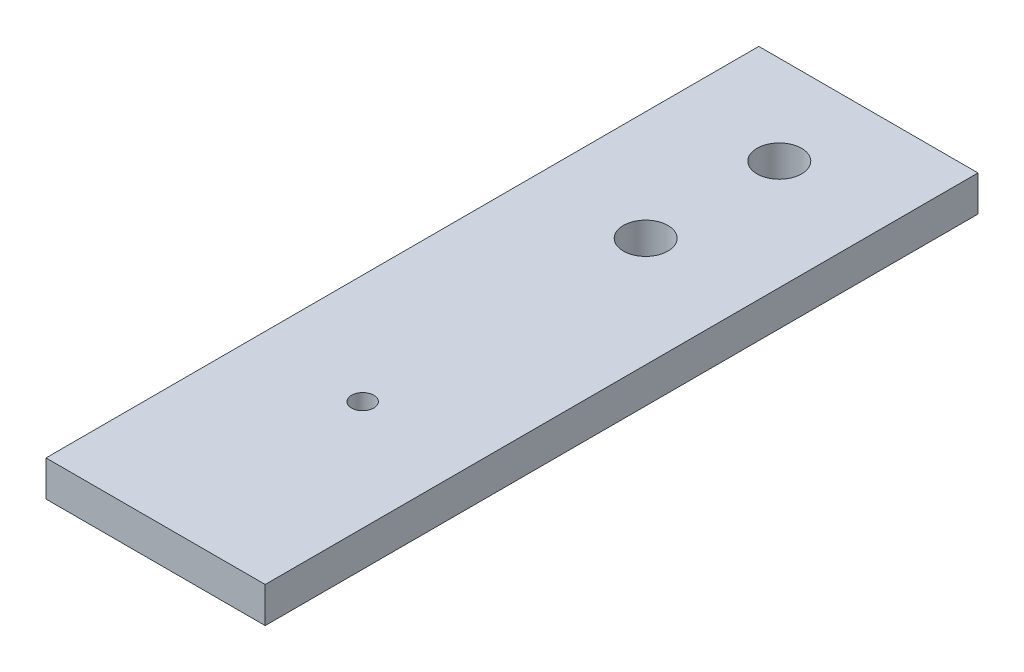
from build123d import *

# Parameters (mm, degrees)
SKETCH1_W                   = 31.242
SKETCH1_H                   = 101.6
BOSS_EXTRUDE1_DEPTH         = 5.08
F_1_4_0_25_DIAMETER_HOLE1_D = 6.35
F_1_8_0_1250_DOWEL_HOLE1_D  = 3.175


with BuildPart() as part:
    # Sketch1 → Boss-Extrude1 (new body)
    with BuildSketch(Plane(origin=(0, 0, 0), x_dir=(1, 0, 0), z_dir=(0, 1, 0))):
        with Locations((15.621, 50.8)):
            Rectangle(SKETCH1_W, SKETCH1_H)
    extrude(amount=BOSS_EXTRUDE1_DEPTH)

    # 1/4 (0.25) Diameter Hole1 (through all)
    with Locations(Plane(origin=(0, 0, 0), x_dir=(-1, 0, 0), z_dir=(0, -1, 0))):
        with Locations((-15.621, 69.85), (-15.621, 88.9)):
            Hole(F_1_4_0_25_DIAMETER_HOLE1_D / 2)

    # 1/8 (0.1250) Dowel Hole1 (through all)
    with Locations(Plane(origin=(15.621, 0, -29.5148), x_dir=(0, 0, -1), z_dir=(0, -1, 0))):
        with Locations((0, 0)):
            Hole(F_1_8_0_1250_DOWEL_HOLE1_D / 2)


solid = part.part
